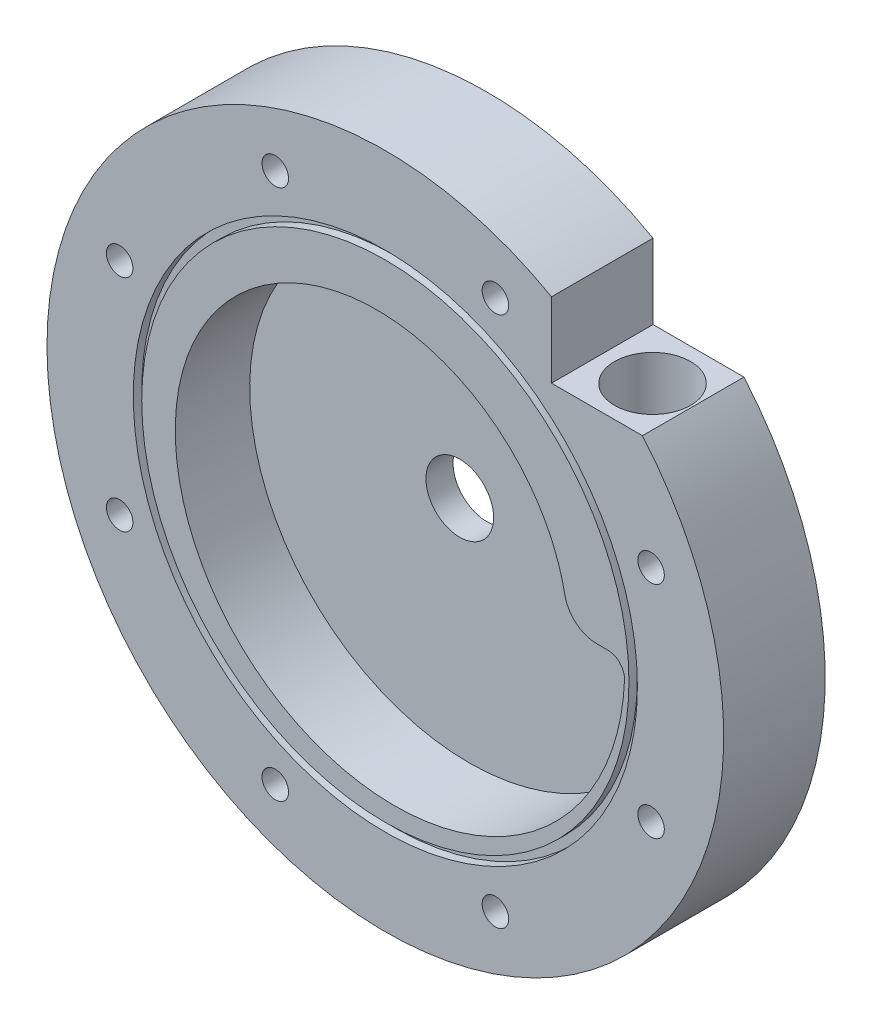
from build123d import *

# Parameters (mm, degrees)
SKETCH1_R                         = 63.5
WALLS_DEPTH                       = 9.07288
SKETCH1_3_R                       = 63.5
SKETCH1_3_R_2                     = 6.35
FLOOR_2_DEPTH                     = 5.08
SKETCH5_R                         = 63.5
CEILING_CONSTRAINT_DEPTH          = 4.89712
SKETCH7_W                         = 17.072268272
SKETCH7_H                         = 19.05
OUTLET_CUT_DEPTH                  = 23.2250001
OUTLET_HOLE_D                     = 9.525
OUTLET_HOLE_DEPTH                 = 40.64
OUTLET_HOLE_TIP                   = 2.861598698
PIPE_TAP_DRILL_FOR_3_8_TAP1_D     = 14.2748
PIPE_TAP_DRILL_FOR_3_8_TAP1_DEPTH = 12.7
PIPE_TAP_DRILL_FOR_3_8_TAP1_TIP   = 4.288582582
SKETCH16_R                        = 47.3075
SKETCH16_R_2                      = 45.72
SEAL_GROOVE_DEPTH                 = 1.5875
FASTENER_HOLES_D                  = 4.9784
CIRPATTERN1_COUNT                 = 8


with BuildPart() as part:
    # Sketch1 → Walls (new body)
    with BuildSketch(Plane.XY):
        Circle(SKETCH1_R)
        with BuildLine():
            Line((39.693365632, 3.175), (41.723742199, 3.175))
            ThreePointArc((41.723742199, 3.175), (43.968806229, 2.24506403), (44.898742199, 0))
            add(Edge.make_bspline(
                [(34.295865632, 0), (34.29882834, 0.071916436), (34.304754577, 0.21576926), (34.311966888, 0.431642324), (34.317934755, 0.647612083), (34.327139988, 1.079917114), (34.332942166, 2.090306576), (34.279898225, 3.607362054), (34.120445155, 5.41030125), (33.880169476, 7.135326628), (33.552885962, 8.849925684), (33.138997804, 10.54970943), (32.639140351, 12.230302519), (32.054174895, 13.887355713), (31.385187056, 15.516557503), (30.633483645, 17.113645751), (29.800589951, 18.674419055), (28.8882464, 20.194747988), (27.898404875, 21.670586138), (26.833224521, 23.097980967), (25.695067067, 24.473084443), (24.486491635, 25.79216345), (23.210249051, 27.051609932), (21.869275652, 28.247950753), (20.466686605, 29.377857252), (19.005768742, 30.438154464), (17.489972932, 31.425829986), (15.922906004, 32.338042467), (14.30832223, 33.172129685), (12.650114403, 33.925616212), (10.95230451, 34.596220626), (9.219034045, 35.18186226), (7.454553956, 35.680667464), (5.663214286, 36.090975363), (3.849453494, 36.411343101), (2.017787512, 36.640550541), (0.172798549, 36.777604421), (-1.680876324, 36.82174194), (-3.538556782, 36.772433779), (-5.395531021, 36.629386524), (-7.247067665, 36.392544506), (-9.088427776, 36.062091031), (-10.914876942, 35.638449008), (-12.721697408, 35.122280961), (-14.504200214, 34.514488429), (-16.257737325, 33.816210747), (-17.977713699, 33.028823219), (-19.659599284, 32.153934663), (-21.298940898, 31.193384362), (-22.891373965, 30.149238397), (-24.43263408, 29.02378539), (-25.918568367, 27.819531655), (-27.345146601, 26.539195761), (-28.708472073, 25.185702541), (-30.004792148, 23.762176529), (-31.230508517, 22.271934869), (-32.382187085, 20.718479685), (-33.456567491, 19.105489956), (-34.450572223, 17.436812889), (-35.361315302, 15.716454831), (-36.186110516, 13.948571725), (-36.92247918, 12.137459144), (-37.568157395, 10.287541924), (-38.121102788, 8.403363415), (-38.579500717, 6.489574383), (-38.941769921, 4.550921586), (-39.206567586, 2.592236057), (-39.372793836, 0.618421113), (-39.439595611, -1.36555987), (-39.406369933, -3.354695889), (-39.272766542, -5.343940927), (-39.038689903, -7.328226707), (-38.704300556, -9.302475561), (-38.270015827, -11.261613379), (-37.736509879, -13.200582609), (-37.104713104, -15.11435526), (-36.375810853, -16.997945903), (-35.551241515, -18.846424601), (-34.632693929, -20.654929769), (-33.622104149, -22.418680905), (-32.521651558, -24.132991168), (-31.333754343, -25.793279776), (-30.061064337, -27.395084183), (-28.706461239, -28.934071999), (-27.273046228, -30.406052641), (-25.764134977, -31.806988658), (-24.18325009, -33.133006716), (-22.534112978, -34.380408214), (-20.820635184, -35.545679488), (-19.046909189, -36.625501594), (-17.217198713, -37.616759627), (-15.335928538, -38.516551562), (-13.407673866, -39.322196576), (-11.437149261, -40.031242854), (-9.429197172, -40.641474829), (-7.388776087, -41.15091985), (-5.32094834, -41.557854256), (-3.230867597, -41.86080884), (-1.123766056, -42.058573678), (0.995058608, -42.150202316), (3.120256518, -42.135015304), (5.246439066, -42.01260305), (7.368192535, -41.782828005), (9.480091844, -41.445826152), (11.576714375, -41.002007803), (13.652653862, -40.452057696), (15.702534288, -39.796934391), (17.72102376, -39.037868953), (19.702848338, -38.176362944), (21.642805765, -37.214185701), (23.535779073, -36.153370925), (25.376750026, -34.996212572), (27.16081237, -33.745260064), (28.883184839, -32.403312824), (30.539223912, -30.973414146), (32.12443625, -29.458844418), (33.634490817, -27.863113704), (35.065230621, -26.189953715), (36.412684063, -24.44330917), (37.673075861, -22.62732858), (38.842837509, -20.746354475), (39.91861725, -18.804913085), (40.897289536, -16.807703518), (41.775963949, -14.759586443), (42.55199355, -12.665572318), (43.22298264, -10.530809183), (43.786793912, -8.360570051), (44.241554967, -6.16023993), (44.571284542, -4.028278167), (44.740560267, -2.440845712), (44.813728039, -1.50376068), (44.839477521, -1.128293226), (44.857032226, -0.846470241), (44.872782179, -0.564469795), (44.886887576, -0.282309503), (44.894790326, -0.094111086), (44.898742199, 0)],
                knots=[0, 0, 0, 0, 0.000870248, 0.001740737, 0.002611466, 0.003482435, 0.006968712, 0.014826916, 0.02182843, 0.028845498, 0.035878186, 0.042926556, 0.049990663, 0.057070561, 0.064166299, 0.071277925, 0.078405484, 0.085549018, 0.092708569, 0.099884178, 0.107075882, 0.11428372, 0.121507729, 0.128747942, 0.136004396, 0.143277124, 0.150566158, 0.157871532, 0.165193276, 0.172531421, 0.179885999, 0.187257038, 0.194644569, 0.202048619, 0.209469218, 0.216906393, 0.224360171, 0.23183058, 0.239317647, 0.246821397, 0.254341857, 0.261879053, 0.269433009, 0.277003751, 0.284591303, 0.292195691, 0.299816937, 0.307455067, 0.315110103, 0.32278207, 0.33047099, 0.338176886, 0.345899781, 0.353639698, 0.361396658, 0.369170685, 0.376961799, 0.384770023, 0.392595378, 0.400437886, 0.408297568, 0.416174444, 0.424068536, 0.431979864, 0.439908449, 0.447854312, 0.455817472, 0.463797949, 0.471795764, 0.479810937, 0.487843486, 0.495893432, 0.503960795, 0.512045592, 0.520147845, 0.52826757, 0.536404789, 0.544559519, 0.552731779, 0.560921587, 0.569128963, 0.577353925, 0.58559649, 0.593856678, 0.602134505, 0.610429991, 0.618743153, 0.627074009, 0.635422576, 0.643788872, 0.652172916, 0.660574723, 0.668994312, 0.677431699, 0.685886903, 0.69435994, 0.702850826, 0.71135958, 0.719886217, 0.728430756, 0.736993211, 0.745573601, 0.754171941, 0.762788249, 0.771422539, 0.78007483, 0.788745137, 0.797433476, 0.806139864, 0.814864316, 0.823606849, 0.832367479, 0.841146221, 0.849943091, 0.858758106, 0.86759128, 0.87644263, 0.885312171, 0.894199918, 0.903105888, 0.912030094, 0.920972554, 0.929933282, 0.938912294, 0.947909603, 0.956925227, 0.96595918, 0.975011476, 0.984082132, 0.992034027, 0.994308583, 0.995446291, 0.996584287, 0.997722571, 0.998861142, 1, 1, 1, 1], degree=3))
            ThreePointArc((34.295865632, 0), (35.407115632, -1.11125), (36.518365632, 0))
            ThreePointArc((36.518365632, 0), (37.448301602, 2.24506403), (39.693365632, 3.175))
        make_face(mode=Mode.SUBTRACT)
    extrude(amount=WALLS_DEPTH)

    # Sketch1_3 → Floor 2 (add)
    with BuildSketch(Plane.XY):
        Circle(SKETCH1_3_R)
        Circle(SKETCH1_3_R_2, mode=Mode.SUBTRACT)
    extrude(amount=-FLOOR_2_DEPTH)

    # Sketch5 → Ceiling Constraint (add)
    with BuildSketch(Plane.XY.offset(9.07288)):
        Circle(SKETCH5_R)
        with BuildLine():
            ThreePointArc((33.687612918, 8.123242193), (35.802537749, 4.571401559), (39.693365632, 3.175))
            Line((39.693365632, 3.175), (41.723742199, 3.175))
            ThreePointArc((41.723742199, 3.175), (43.968806229, 2.24506403), (44.898742199, 0))
            add(Edge.make_bspline(
                [(33.687612918, 8.123242193), (33.64058621, 8.364530199), (33.473407427, 9.176333484), (33.138997804, 10.54970943), (32.639140351, 12.230302519), (32.054174895, 13.887355713), (31.385187056, 15.516557503), (30.633483645, 17.113645751), (29.800589951, 18.674419055), (28.8882464, 20.194747988), (27.898404875, 21.670586138), (26.833224521, 23.097980967), (25.695067067, 24.473084443), (24.486491635, 25.79216345), (23.210249051, 27.051609932), (21.869275652, 28.247950753), (20.466686605, 29.377857252), (19.005768742, 30.438154464), (17.489972932, 31.425829986), (15.922906004, 32.338042467), (14.30832223, 33.172129685), (12.650114403, 33.925616212), (10.95230451, 34.596220626), (9.219034045, 35.18186226), (7.454553956, 35.680667464), (5.663214286, 36.090975363), (3.849453494, 36.411343101), (2.017787512, 36.640550541), (0.172798549, 36.777604421), (-1.680876324, 36.82174194), (-3.538556782, 36.772433779), (-5.395531021, 36.629386524), (-7.247067665, 36.392544506), (-9.088427776, 36.062091031), (-10.914876942, 35.638449008), (-12.721697408, 35.122280961), (-14.504200214, 34.514488429), (-16.257737325, 33.816210747), (-17.977713699, 33.028823219), (-19.659599284, 32.153934663), (-21.298940898, 31.193384362), (-22.891373965, 30.149238397), (-24.43263408, 29.02378539), (-25.918568367, 27.819531655), (-27.345146601, 26.539195761), (-28.708472073, 25.185702541), (-30.004792148, 23.762176529), (-31.230508517, 22.271934869), (-32.382187085, 20.718479685), (-33.456567491, 19.105489956), (-34.450572223, 17.436812889), (-35.361315302, 15.716454831), (-36.186110516, 13.948571725), (-36.92247918, 12.137459144), (-37.568157395, 10.287541924), (-38.121102788, 8.403363415), (-38.579500717, 6.489574383), (-38.941769921, 4.550921586), (-39.206567586, 2.592236057), (-39.372793836, 0.618421113), (-39.439595611, -1.36555987), (-39.406369933, -3.354695889), (-39.272766542, -5.343940927), (-39.038689903, -7.328226707), (-38.704300556, -9.302475561), (-38.270015827, -11.261613379), (-37.736509879, -13.200582609), (-37.104713104, -15.11435526), (-36.375810853, -16.997945903), (-35.551241515, -18.846424601), (-34.632693929, -20.654929769), (-33.622104149, -22.418680905), (-32.521651558, -24.132991168), (-31.333754343, -25.793279776), (-30.061064337, -27.395084183), (-28.706461239, -28.934071999), (-27.273046228, -30.406052641), (-25.764134977, -31.806988658), (-24.18325009, -33.133006716), (-22.534112978, -34.380408214), (-20.820635184, -35.545679488), (-19.046909189, -36.625501594), (-17.217198713, -37.616759627), (-15.335928538, -38.516551562), (-13.407673866, -39.322196576), (-11.437149261, -40.031242854), (-9.429197172, -40.641474829), (-7.388776087, -41.15091985), (-5.32094834, -41.557854256), (-3.230867597, -41.86080884), (-1.123766056, -42.058573678), (0.995058608, -42.150202316), (3.120256518, -42.135015304), (5.246439066, -42.01260305), (7.368192535, -41.782828005), (9.480091844, -41.445826152), (11.576714375, -41.002007803), (13.652653862, -40.452057696), (15.702534288, -39.796934391), (17.72102376, -39.037868953), (19.702848338, -38.176362944), (21.642805765, -37.214185701), (23.535779073, -36.153370925), (25.376750026, -34.996212572), (27.16081237, -33.745260064), (28.883184839, -32.403312824), (30.539223912, -30.973414146), (32.12443625, -29.458844418), (33.634490817, -27.863113704), (35.065230621, -26.189953715), (36.412684063, -24.44330917), (37.673075861, -22.62732858), (38.842837509, -20.746354475), (39.91861725, -18.804913085), (40.897289536, -16.807703518), (41.775963949, -14.759586443), (42.55199355, -12.665572318), (43.22298264, -10.530809183), (43.786793912, -8.360570051), (44.241554967, -6.16023993), (44.571284542, -4.028278167), (44.740560267, -2.440845712), (44.813728039, -1.50376068), (44.839477521, -1.128293226), (44.857032226, -0.846470241), (44.872782179, -0.564469795), (44.886887576, -0.282309503), (44.894790326, -0.094111086), (44.898742199, 0)],
                knots=[0.032905983, 0.032905983, 0.032905983, 0.032905983, 0.035878186, 0.042926556, 0.049990663, 0.057070561, 0.064166299, 0.071277925, 0.078405484, 0.085549018, 0.092708569, 0.099884178, 0.107075882, 0.11428372, 0.121507729, 0.128747942, 0.136004396, 0.143277124, 0.150566158, 0.157871532, 0.165193276, 0.172531421, 0.179885999, 0.187257038, 0.194644569, 0.202048619, 0.209469218, 0.216906393, 0.224360171, 0.23183058, 0.239317647, 0.246821397, 0.254341857, 0.261879053, 0.269433009, 0.277003751, 0.284591303, 0.292195691, 0.299816937, 0.307455067, 0.315110103, 0.32278207, 0.33047099, 0.338176886, 0.345899781, 0.353639698, 0.361396658, 0.369170685, 0.376961799, 0.384770023, 0.392595378, 0.400437886, 0.408297568, 0.416174444, 0.424068536, 0.431979864, 0.439908449, 0.447854312, 0.455817472, 0.463797949, 0.471795764, 0.479810937, 0.487843486, 0.495893432, 0.503960795, 0.512045592, 0.520147845, 0.52826757, 0.536404789, 0.544559519, 0.552731779, 0.560921587, 0.569128963, 0.577353925, 0.58559649, 0.593856678, 0.602134505, 0.610429991, 0.618743153, 0.627074009, 0.635422576, 0.643788872, 0.652172916, 0.660574723, 0.668994312, 0.677431699, 0.685886903, 0.69435994, 0.702850826, 0.71135958, 0.719886217, 0.728430756, 0.736993211, 0.745573601, 0.754171941, 0.762788249, 0.771422539, 0.78007483, 0.788745137, 0.797433476, 0.806139864, 0.814864316, 0.823606849, 0.832367479, 0.841146221, 0.849943091, 0.858758106, 0.86759128, 0.87644263, 0.885312171, 0.894199918, 0.903105888, 0.912030094, 0.920972554, 0.929933282, 0.938912294, 0.947909603, 0.956925227, 0.96595918, 0.975011476, 0.984082132, 0.992034027, 0.994308583, 0.995446291, 0.996584287, 0.997722571, 0.998861142, 1, 1, 1, 1], degree=3))
        make_face(mode=Mode.SUBTRACT)
    extrude(amount=CEILING_CONSTRAINT_DEPTH)

    # Sketch7 → Outlet Cut (cut, through all)
    with BuildSketch(Plane(origin=(0, 41.275, 0), x_dir=(-1, 0, 0), z_dir=(0, -1, 0))):
        with Locations((-39.719688052, -4.445)):
            Rectangle(SKETCH7_W, SKETCH7_H)
    extrude(amount=-OUTLET_CUT_DEPTH, mode=Mode.SUBTRACT)

    # Outlet Hole
    with Locations(Plane(origin=(40.708553916, 41.275, 4.53644), x_dir=(0, 0, 1), z_dir=(0, 1, 0))):
        with Locations((0, 0)):
            Hole(OUTLET_HOLE_D / 2, depth=OUTLET_HOLE_DEPTH)
            with Locations((0, 0, -(OUTLET_HOLE_DEPTH + OUTLET_HOLE_TIP / 2))):  # 118° drill point
                Cone(0, OUTLET_HOLE_D / 2, OUTLET_HOLE_TIP, mode=Mode.SUBTRACT)

    # Pipe Tap Drill for 3_8 Tap1
    with Locations(Plane(origin=(0, 41.275, 0), x_dir=(1, 0, 0), z_dir=(0, 1, 0))):
        with Locations((40.708553916, -4.53644)):
            Hole(PIPE_TAP_DRILL_FOR_3_8_TAP1_D / 2, depth=PIPE_TAP_DRILL_FOR_3_8_TAP1_DEPTH)
            with Locations((0, 0, -(PIPE_TAP_DRILL_FOR_3_8_TAP1_DEPTH + PIPE_TAP_DRILL_FOR_3_8_TAP1_TIP / 2))):  # 118° drill point
                Cone(0, PIPE_TAP_DRILL_FOR_3_8_TAP1_D / 2, PIPE_TAP_DRILL_FOR_3_8_TAP1_TIP, mode=Mode.SUBTRACT)

    # Sketch16 → Seal Groove (cut)
    with BuildSketch(Plane.XY.offset(13.97)):
        Circle(SKETCH16_R)
        Circle(SKETCH16_R_2, mode=Mode.SUBTRACT)
    extrude(amount=-SEAL_GROOVE_DEPTH, mode=Mode.SUBTRACT)

    # Fastener Holes (through all)
    with Locations(Plane.XY.offset(13.97)):
        with Locations((49.866397767, 20.655338262)):
            fastener_holes = Hole(FASTENER_HOLES_D / 2)

    # CirPattern1: Fastener Holes ×8 about axis
    cirpattern1_axis = Axis((0, 0, 0), (0, 0, 1))
    for i in range(1, CIRPATTERN1_COUNT):
        add(fastener_holes.rotate(cirpattern1_axis, i * 360 / CIRPATTERN1_COUNT), mode=Mode.SUBTRACT)


solid = part.part
